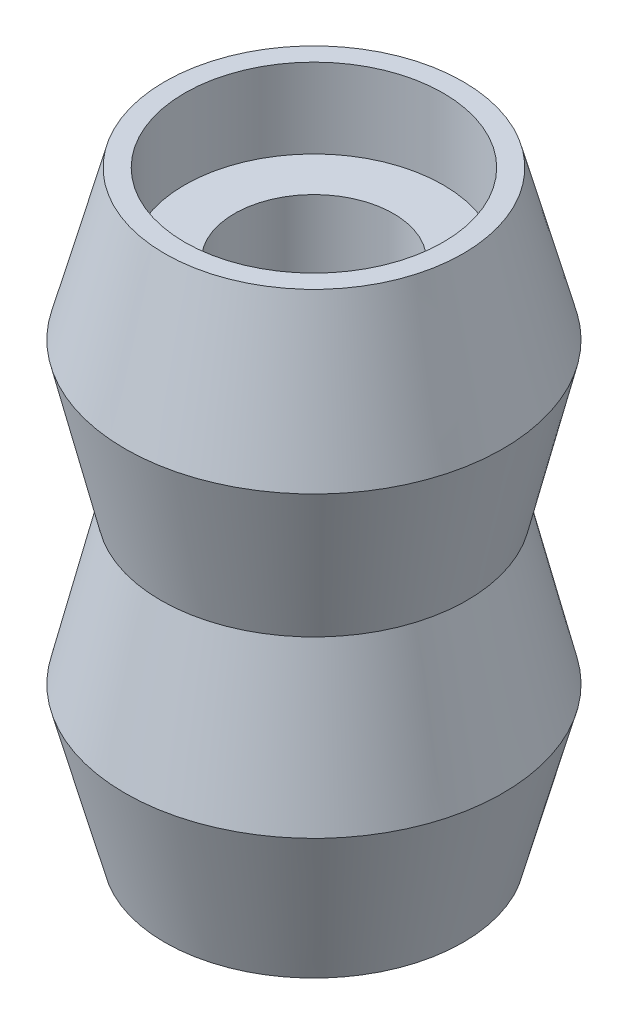
from build123d import *


with BuildPart() as part:
    # Sketch1 → Revolve1 (revolve)
    with BuildSketch(Plane.XY):
        Polygon((4, -7.807683218), (4, 14.192316782), (6.5, 14.192316782), (6.5, 18.192316782), (7.5, 18.192316782), (9.5, 10.692316782), (7.7, 3.192316782), (9.5, -4.307683218), (7.5, -11.807683218), (6.5, -11.807683218), (6.5, -7.807683218), align=None)
    revolve(axis=Axis((0, 42.323455848, 0), (0, -1, 0)))


solid = part.part
